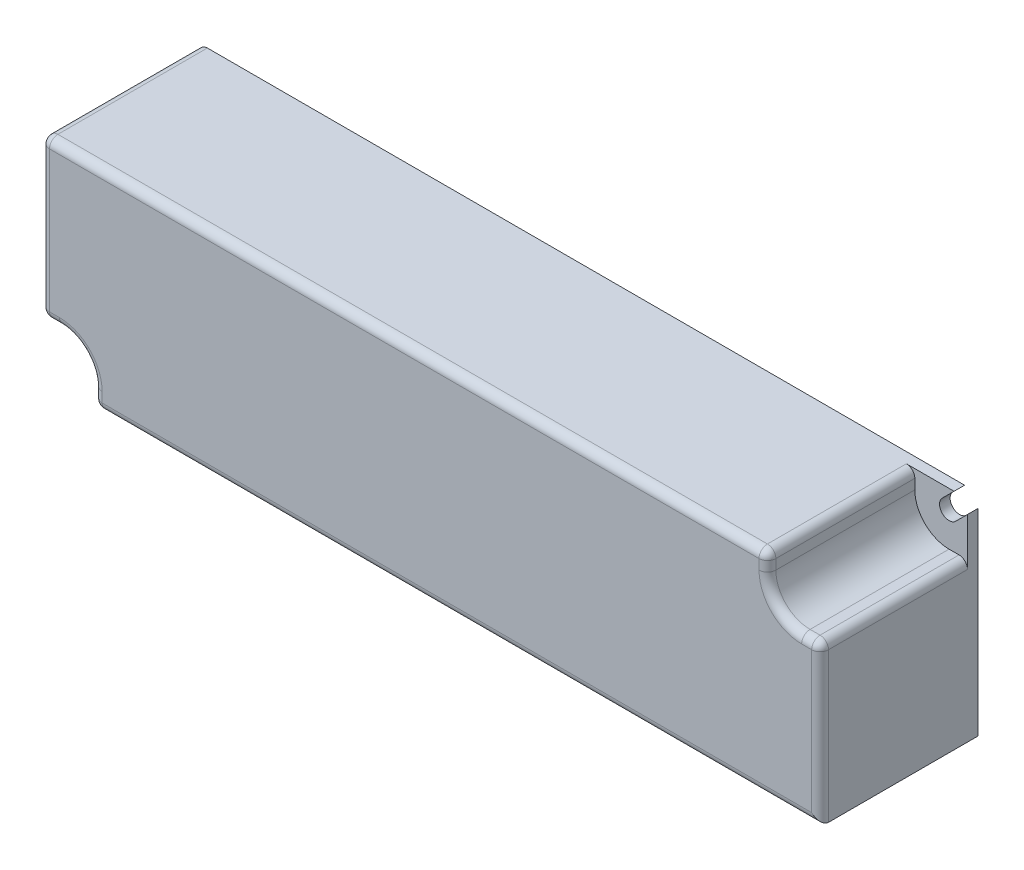
from build123d import *

# Parameters (mm, degrees)
SKETCH1_W           = 148
SKETCH1_H           = 40
BOSS_EXTRUDE1_DEPTH = 30
CUT_EXTRUDE1_DEPTH  = 30
CUT_EXTRUDE2_DEPTH  = 28
FILLET1_R           = 1.6


with BuildPart() as part:
    # Sketch1 → Boss-Extrude1 (new body)
    with BuildSketch(Plane.XY):
        Rectangle(SKETCH1_W, SKETCH1_H)
    extrude(amount=BOSS_EXTRUDE1_DEPTH)

    # Sketch2 → Cut-Extrude1 (cut)
    with BuildSketch(Plane.XY.offset(30)):
        with BuildLine():
            Line((69.227207794, 17.772792206), (73.727238034, 22.272822446))
            Line((73.727238034, 22.272822446), (76.272822446, 19.727238034))
            Line((76.272822446, 19.727238034), (71.772792206, 15.227207794))
            ThreePointArc((71.772792206, 15.227207794), (69.227207794, 15.227207794), (69.227207794, 17.772792206))
        make_face()
        with BuildLine():
            Line((-69.227207794, -17.772792206), (-73.727238034, -22.272822446))
            Line((-73.727238034, -22.272822446), (-76.272822446, -19.727238034))
            Line((-76.272822446, -19.727238034), (-71.772792206, -15.227207794))
            ThreePointArc((-71.772792206, -15.227207794), (-69.227207794, -15.227207794), (-69.227207794, -17.772792206))
        make_face()
    extrude(amount=-CUT_EXTRUDE1_DEPTH, mode=Mode.SUBTRACT)

    # Sketch3 → Cut-Extrude2 (cut)
    with BuildSketch(Plane.XY.offset(30)):
        with BuildLine():
            Line((64, 27.706839185), (64, 16.5))
            ThreePointArc((64, 16.5), (65.903805922, 11.903805922), (70.5, 10))
            Line((70.5, 10), (82.036431888, 10))
            Line((82.036431888, 10), (64, 27.706839185))
        make_face()
        with BuildLine():
            Line((-64, -27.706839185), (-64, -16.5))
            ThreePointArc((-64, -16.5), (-65.903805922, -11.903805922), (-70.5, -10))
            Line((-70.5, -10), (-82.036431888, -10))
            Line((-82.036431888, -10), (-64, -27.706839185))
        make_face()
    extrude(amount=-CUT_EXTRUDE2_DEPTH, mode=Mode.SUBTRACT)

    # Fillet1
    fillet1_edges = [part.edges().sort_by_distance(p)[0] for p in [
        (-74, 5, 30),
        (74, -5, 30),
        (-5, 20, 30),
        (74, 10, 16),
        (64, 20, 16),
        (72.25, 10, 30),
        (64, 18.25, 30),
        (65.903805922, 11.903805922, 30),
        (-74, 20, 15),
        (5, -20, 30),
        (-74, -10, 16),
        (-64, -20, 16),
        (-72.25, -10, 30),
        (-64, -18.25, 30),
        (-65.903805922, -11.903805922, 30),
    ]]
    fillet(fillet1_edges, radius=FILLET1_R)


solid = part.part
